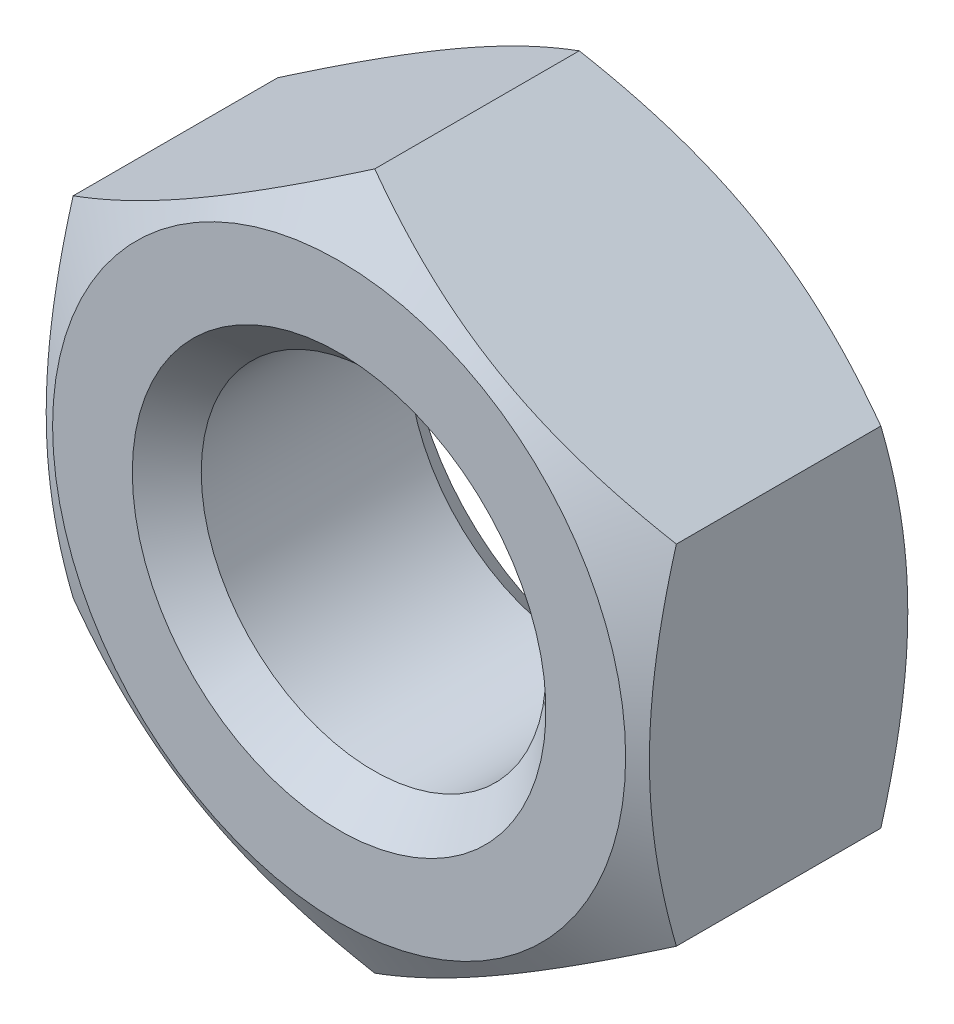
from build123d import *

# Parameters (mm, degrees)
SKETCH_1_W               = 5
SKETCH_1_H               = 3.2
SKETCH_2_OUTSIDE_W       = 14.9
SKETCH_2_OUTSIDE_H       = 14.9
CUT_EXTRUDE_1_DEPTH      = 3.2
SKETCH_3_R               = 2
CUT_EXTRUDE_2_DEPTH      = 1
CUT_EXTRUDE_2_DEPTH_BACK = 4.2
CHAMFER_1_SIZE           = 0.4


with BuildPart() as part:
    # Эскиз1 → Повернуть1 (revolve)
    with BuildSketch(Plane(origin=(0, 0, 0), x_dir=(1, 0, 0), z_dir=(0, 1, 0))):
        with Locations((-2.5, 1.6)):
            Rectangle(SKETCH_1_W, SKETCH_1_H)
    revolve(axis=Axis((0, 0, 0), (0, 0, -1)))

    # Эскиз2 outside → Вырез-Вытянуть1 (cut)
    with BuildSketch(Plane.XY):
        Rectangle(SKETCH_2_OUTSIDE_W, SKETCH_2_OUTSIDE_H)
        Polygon((3.5, -2.020725942), (3.5, 2.020725942), (0, 4.041451884), (-3.5, 2.020725942), (-3.5, -2.020725942), (0, -4.041451884), align=None, mode=Mode.SUBTRACT)
    extrude(amount=-CUT_EXTRUDE_1_DEPTH, mode=Mode.SUBTRACT)

    # Эскиз3 → Вырез-Вытянуть2 (cut, two sides)
    with BuildSketch(Plane.XY) as cut_extrude_2_sk:
        Circle(SKETCH_3_R)
    extrude(amount=CUT_EXTRUDE_2_DEPTH, mode=Mode.SUBTRACT)
    extrude(cut_extrude_2_sk.sketch, amount=-CUT_EXTRUDE_2_DEPTH_BACK, mode=Mode.SUBTRACT)

    # Эскиз4 → Вырез-Повернуть1 (revolve, cut)
    with BuildSketch(Plane(origin=(0, 0, 0), x_dir=(0, 0, -1), z_dir=(1, 0, 0))):
        Polygon((0, 3.325), (0.413643688, 4.041451884), (0, 4.041451884), align=None)
        Polygon((3.2, 3.325), (2.786356312, 4.041451884), (3.2, 4.041451884), align=None)
    revolve(axis=Axis((0, 0, 0), (0, 0, -1)), mode=Mode.SUBTRACT)

    # Фаска1
    chamfer_1_edges = [part.edges().sort_by_distance(p)[0] for p in [
        (-2, 0, -3.2),
        (-2, 0, 0),
    ]]
    chamfer(chamfer_1_edges, length=CHAMFER_1_SIZE)


solid = part.part
